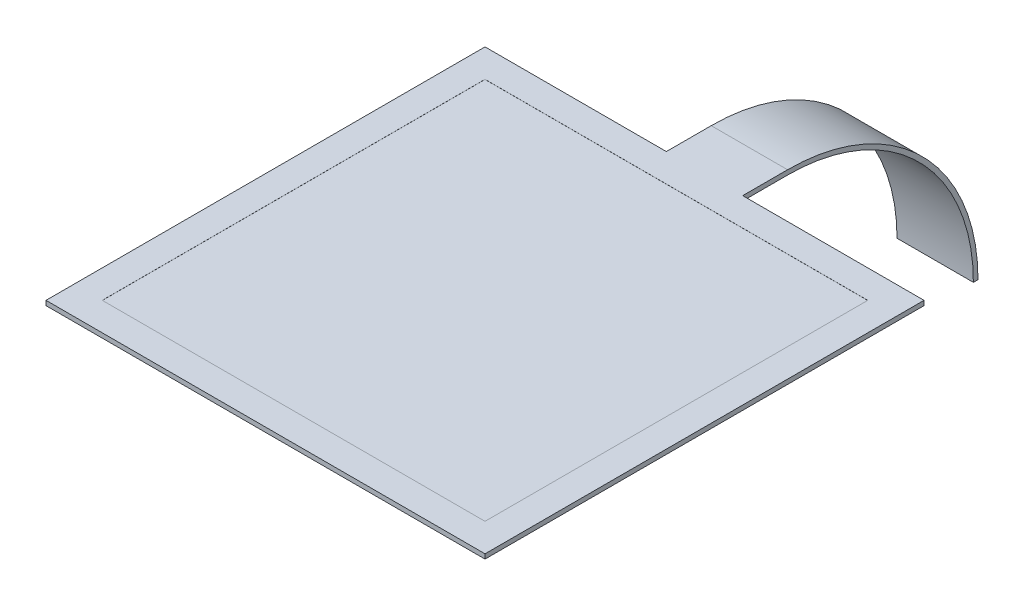
from build123d import *

# Parameters (mm, degrees)
BOSS_EXTRUDE1_DEPTH = 0.23
SKETCH2_W           = 38.1
SKETCH2_H           = 38.1
CUT_EXTRUDE1_DEPTH  = 0.01
BOSS_EXTRUDE2_DEPTH = 3.8
CUT_EXTRUDE2_DEPTH  = 3.8


with BuildPart() as part:
    # Sketch1 → Boss-Extrude1 (new body, symmetric)
    with BuildSketch(Plane(origin=(0, 0, 0), x_dir=(1, 0, 0), z_dir=(0, 1, 0))):
        Polygon((3.8, 21.85), (21.85, 21.85), (21.85, -21.85), (-21.85, -21.85), (-21.85, 21.85), (-3.8, 21.85), (-3.8, 61.95), (3.8, 61.95), align=None)
    extrude(amount=BOSS_EXTRUDE1_DEPTH, both=True)

    # Sketch2 → Cut-Extrude1 (cut)
    with BuildSketch(Plane(origin=(0, 0.23, 0), x_dir=(1, 0, 0), z_dir=(0, 1, 0))):
        Rectangle(SKETCH2_W, SKETCH2_H)
    extrude(amount=-CUT_EXTRUDE1_DEPTH, mode=Mode.SUBTRACT)

    # Sketch3 → Boss-Extrude2 (add, symmetric)
    with BuildSketch(Plane(origin=(0, 0, 0), x_dir=(0, 0, -1), z_dir=(1, 0, 0))):
        with BuildLine():
            Line((26.315584349, 0.23), (26.315584349, -0.23))
            ThreePointArc((26.315584349, -0.23), (39.394431992, -5.647436074), (44.811868066, -18.726283717))
            Line((44.811868066, -18.726283717), (45.271868066, -18.726283717))
            ThreePointArc((45.271868066, -18.726283717), (39.719701111, -5.322166955), (26.315584349, 0.23))
        make_face()
    extrude(amount=BOSS_EXTRUDE2_DEPTH, both=True)

    # Sketch4 → Cut-Extrude2 (cut, symmetric)
    with BuildSketch(Plane(origin=(0, 0, 0), x_dir=(0, 0, -1), z_dir=(1, 0, 0))):
        with BuildLine():
            Line((30.466268753, -0.23), (61.95, -0.23))
            Line((61.95, -0.23), (61.95, 0.23))
            Line((61.95, 0.23), (26.315584349, 0.23))
            ThreePointArc((26.315584349, 0.23), (28.403632542, 0.114649039), (30.466268753, -0.23))
        make_face()
    extrude(amount=CUT_EXTRUDE2_DEPTH, both=True, mode=Mode.SUBTRACT)


solid = part.part
